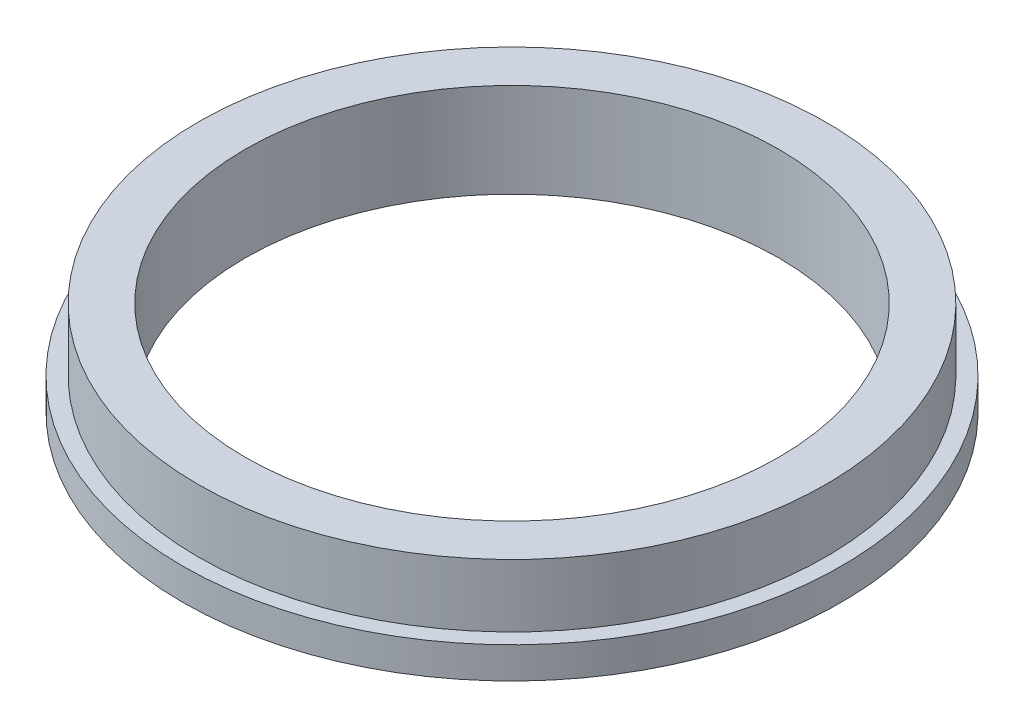
from build123d import *

# Parameters (mm, degrees)
SKETCH1_R           = 52.5
BOSS_EXTRUDE1_DEPTH = 5
SKETCH2_R           = 50
SKETCH2_R_2         = 42.5
BOSS_EXTRUDE2_DEPTH = 10
SKETCH3_R           = 42.5
CUT_EXTRUDE1_DEPTH  = 6


with BuildPart() as part:
    # Sketch1 → Boss-Extrude1 (new body)
    with BuildSketch(Plane(origin=(0, 0, 0), x_dir=(1, 0, 0), z_dir=(0, 1, 0))):
        Circle(SKETCH1_R)
    extrude(amount=BOSS_EXTRUDE1_DEPTH)

    # Sketch2 → Boss-Extrude2 (add)
    with BuildSketch(Plane(origin=(0, 5, 0), x_dir=(1, 0, 0), z_dir=(0, 1, 0))):
        Circle(SKETCH2_R)
        Circle(SKETCH2_R_2, mode=Mode.SUBTRACT)
    extrude(amount=BOSS_EXTRUDE2_DEPTH)

    # Sketch3 → Cut-Extrude1 (cut, through all)
    with BuildSketch(Plane(origin=(0, 5, 0), x_dir=(1, 0, 0), z_dir=(0, 1, 0))):
        Circle(SKETCH3_R)
    extrude(amount=-CUT_EXTRUDE1_DEPTH, mode=Mode.SUBTRACT)


solid = part.part
